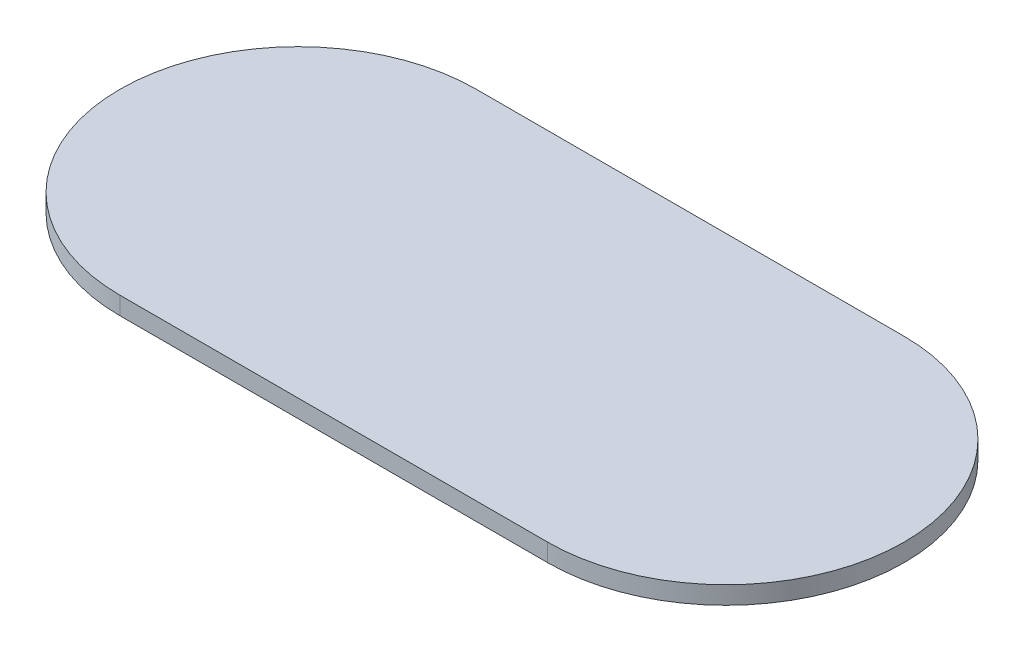
from build123d import *

# Parameters (mm, degrees)
BOSS_EXTRUDE1_DEPTH = 6.35


with BuildPart() as part:
    # Sketch1 → Boss-Extrude1 (new body)
    with BuildSketch(Plane(origin=(0, 0, 0), x_dir=(1, 0, 0), z_dir=(0, 1, 0))):
        with BuildLine():
            Line((-76.2, 0), (76.2, 0))
            ThreePointArc((76.2, 0), (139.7, -63.5), (76.2, -127))
            Line((76.2, -127), (-76.2, -127))
            ThreePointArc((-76.2, -127), (-139.7, -63.5), (-76.2, 0))
        make_face()
    extrude(amount=BOSS_EXTRUDE1_DEPTH)


solid = part.part
